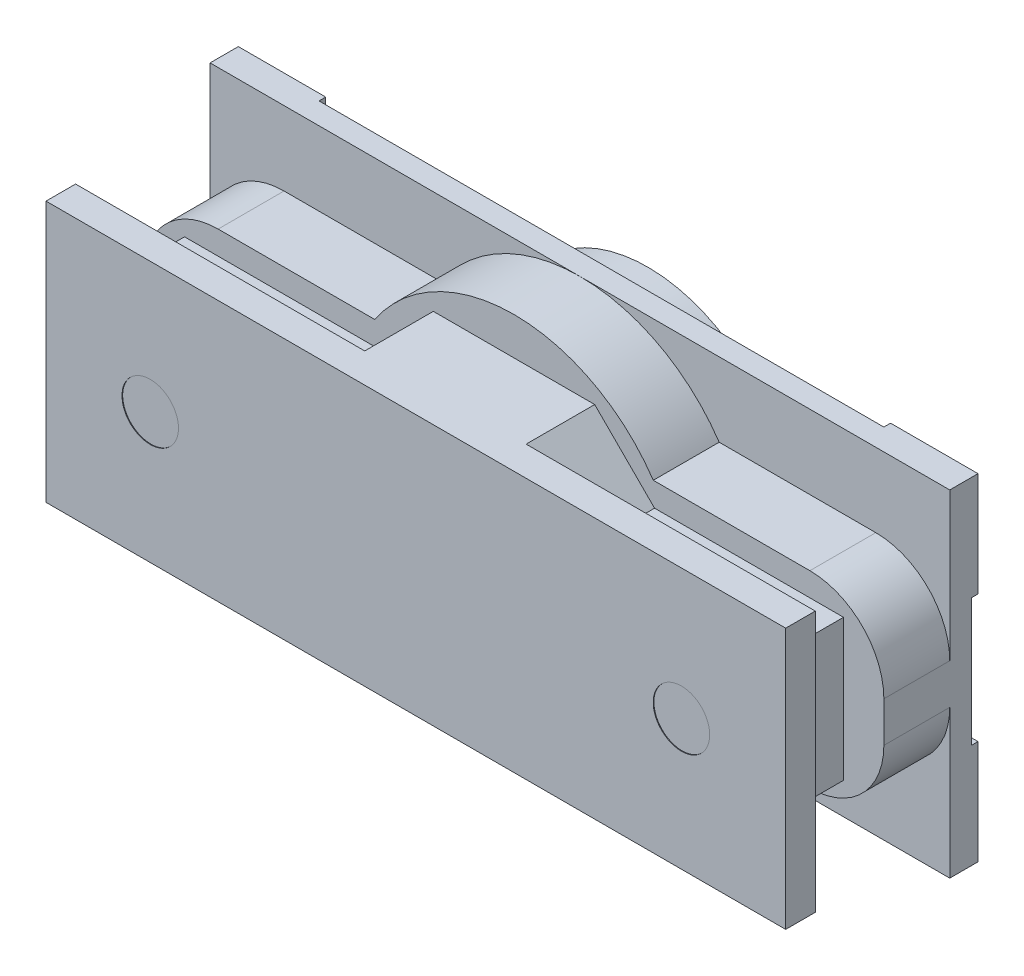
from build123d import *

# Parameters (mm, degrees)
SZKIC1_W                    = 110
SZKIC1_H                    = 50
DODANIE_WYCI_GNI_CIE1_DEPTH = 4.2
SZKIC2_R                    = 21.15
DODANIE_WYCI_GNI_CIE2_DEPTH = 5.9
DODANIE_WYCI_GNI_CIE3_DEPTH = 9.8
ZAOKR_GLENIE1_R             = 11
DODANIE_WYCI_GNI_CIE4_DEPTH = 10.2
SZKIC5_W                    = 110
SZKIC5_H                    = 38.8
DODANIE_WYCI_GNI_CIE5_DEPTH = 4.4
SZKIC6_R                    = 4.2
WYTNIJ_WYCI_GNI_CIE1_DEPTH  = 0.1
SZKIC7_R                    = 9.3
SZKIC7_R_2                  = 7
WYTNIJ_WYCI_GNI_CIE2_DEPTH  = 1


with BuildPart() as part:
    # Szkic1 → Dodanie-wyciągnięcie1 (new body)
    with BuildSketch(Plane.XY):
        Rectangle(SZKIC1_W, SZKIC1_H)
    extrude(amount=DODANIE_WYCI_GNI_CIE1_DEPTH)

    # Szkic2 → Dodanie-wyciągnięcie2 (add)
    with BuildSketch(Plane.XY):
        Circle(SZKIC2_R)
    extrude(amount=-DODANIE_WYCI_GNI_CIE2_DEPTH)

    # Szkic3 → Dodanie-wyciągnięcie3 (add)
    with BuildSketch(Plane.XY.offset(4.2)):
        with BuildLine():
            Line((-55, 14), (-55, -14))
            Line((-55, -14), (-20.712315177, -14))
            ThreePointArc((-20.712315177, -14), (-25, 0), (-20.712315177, 14))
            Line((-20.712315177, 14), (-55, 14))
        make_face()
        with BuildLine():
            ThreePointArc((-20.712315177, 14), (-25, 0), (-20.712315177, -14))
            Line((-20.712315177, -14), (20.712315177, -14))
            ThreePointArc((20.712315177, -14), (23.904056972, -7.32093302), (25, 0))
            ThreePointArc((25, 0), (23.904056972, 7.32093302), (20.712315177, 14))
            Line((20.712315177, 14), (-20.712315177, 14))
        make_face()
        with BuildLine():
            ThreePointArc((20.712315177, 14), (0, 25), (-20.712315177, 14))
            Line((-20.712315177, 14), (20.712315177, 14))
        make_face()
        with BuildLine():
            ThreePointArc((25, 0), (23.904056972, -7.32093302), (20.712315177, -14))
            Line((20.712315177, -14), (55, -14))
            Line((55, -14), (55, 14))
            Line((55, 14), (20.712315177, 14))
            ThreePointArc((20.712315177, 14), (23.904056972, 7.32093302), (25, 0))
        make_face()
        with BuildLine():
            Line((20.712315177, -14), (-20.712315177, -14))
            ThreePointArc((-20.712315177, -14), (0, -25), (20.712315177, -14))
        make_face()
    extrude(amount=DODANIE_WYCI_GNI_CIE3_DEPTH)

    # Zaokrąglenie1
    zaokr_glenie1_edges = [part.edges().sort_by_distance(p)[0] for p in [
        (-55, -14, 9.1),
        (55, -14, 9.1),
        (55, 14, 9.1),
        (-55, 14, 9.1),
    ]]
    fillet(zaokr_glenie1_edges, radius=ZAOKR_GLENIE1_R)

    # Szkic4 → Dodanie-wyciągnięcie4 (add)
    with BuildSketch(Plane.XY.offset(14)):
        Polygon((12, 19.4), (20.9, 10.5), (49, 10.5), (49, -10.5), (20.9, -10.5), (12, -19.4), (-12, -19.4), (-20.9, -10.5), (-49, -10.5), (-49, 10.5), (-20.9, 10.5), (-12, 19.4), align=None)
    extrude(amount=DODANIE_WYCI_GNI_CIE4_DEPTH)

    # Szkic5 → Dodanie-wyciągnięcie5 (add)
    with BuildSketch(Plane.XY.offset(24.2)):
        Rectangle(SZKIC5_W, SZKIC5_H)
    extrude(amount=DODANIE_WYCI_GNI_CIE5_DEPTH)

    # Szkic6 → Wytnij-wyciągnięcie1 (cut)
    with BuildSketch(Plane.XY.offset(28.6)):
        with Locations((-39.5, 0)):
            Circle(SZKIC6_R)
        with Locations((39.5, 0)):
            Circle(SZKIC6_R)
    extrude(amount=-WYTNIJ_WYCI_GNI_CIE1_DEPTH, mode=Mode.SUBTRACT)

    # Szkic7 → Wytnij-wyciągnięcie2 (cut)
    with BuildSketch(Plane(origin=(0, 0, 0), x_dir=(-1, 0, 0), z_dir=(0, 0, -1))):
        Polygon((42, 9.5), (42, 25), (-42, 25), (-42, 9.5), (-55, 9.5), (-55, -9.5), (-42, -9.5), (-42, -25), (42, -25), (42, -9.5), (55, -9.5), (55, 9.5), align=None)
        with Locations((-41, 0)):
            Circle(SZKIC7_R, mode=Mode.SUBTRACT)
        with BuildLine():
            ThreePointArc((21.15, 0), (0, -21.15), (-21.15, 0))
            ThreePointArc((-21.15, 0), (0, 21.15), (21.15, 0))
        make_face(mode=Mode.SUBTRACT)
        with Locations((43, 0)):
            Circle(SZKIC7_R, mode=Mode.SUBTRACT)
        with Locations((43, 0)):
            Circle(SZKIC7_R_2)
        with Locations((-41, 0)):
            Circle(SZKIC7_R_2)
    extrude(amount=-WYTNIJ_WYCI_GNI_CIE2_DEPTH, mode=Mode.SUBTRACT)


solid = part.part
